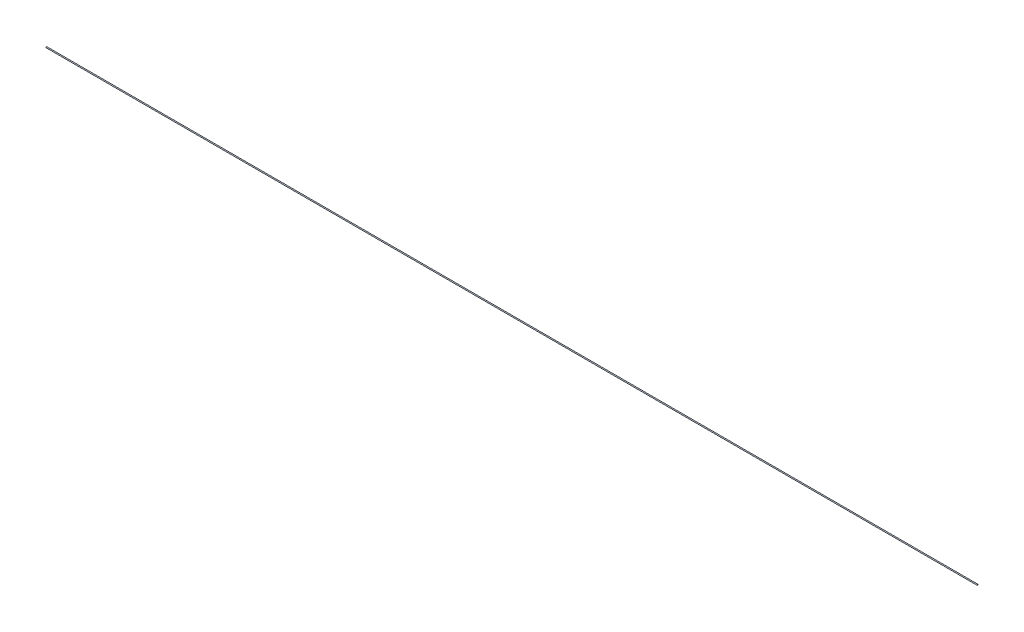
from build123d import *

# Parameters (mm, degrees)
SKETCH1_R           = 5
BOSS_EXTRUDE1_DEPTH = 10000


with BuildPart() as part:
    # Sketch1 → Boss-Extrude1 (new body)
    with BuildSketch(Plane(origin=(0, 0, 0), x_dir=(0, 0, -1), z_dir=(1, 0, 0))):
        Circle(SKETCH1_R)
    extrude(amount=BOSS_EXTRUDE1_DEPTH)


solid = part.part
